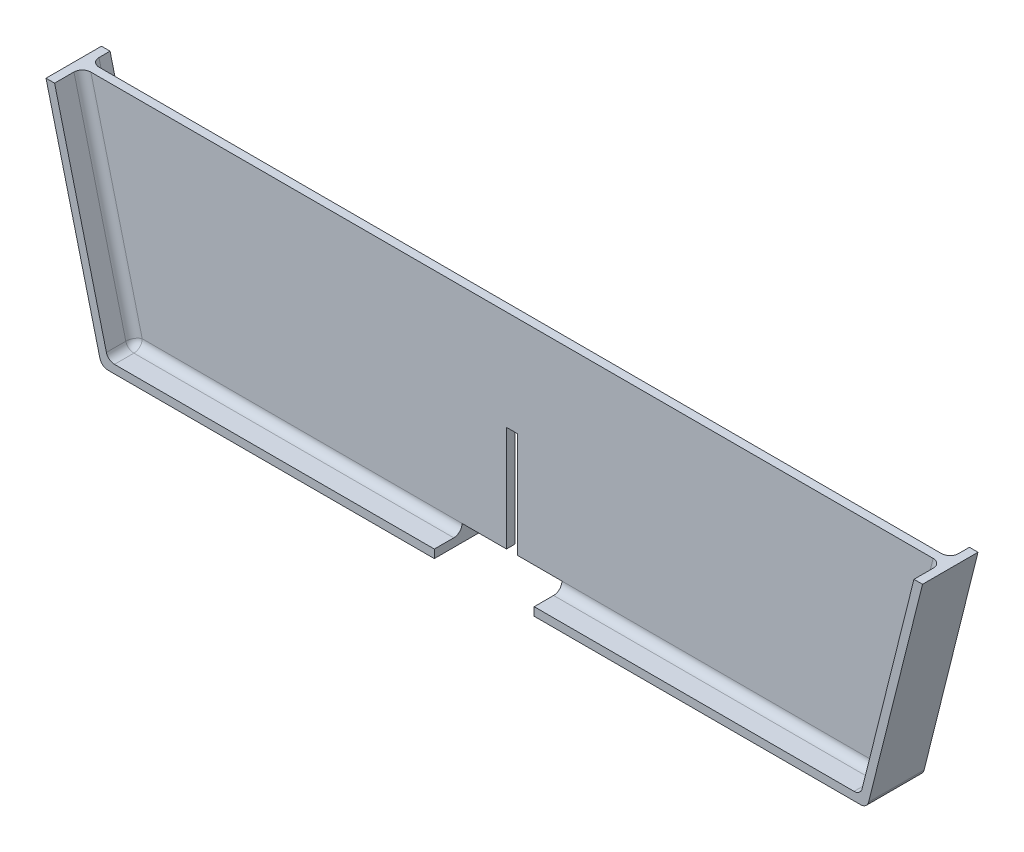
from build123d import *

# Parameters (mm, degrees)
BOSS_EXTRUDE2_DEPTH            = 1.5
BOSS_EXTRUDE3_DEPTH            = 5
BOSS_EXTRUDE3_DEPTH_BACK       = 5
FILLET1_R                      = 1.5
CUT_EXTRUDE1_REACH             = 7
SKETCH6_W                      = 8
SKETCH6_H                      = 3
CUT_EXTRUDE1_DIRECTION_2_DEPTH = 6


with BuildPart() as part:
    # Sketch1 → Boss-Extrude2 (new body)
    with BuildSketch(Plane.XY):
        Polygon((0, 0), (158, 0), (148, -40), (80, -40), (80, -18), (78, -18), (78, -40), (10, -40), align=None)
    extrude(amount=BOSS_EXTRUDE2_DEPTH)

    # Sketch5 → Boss-Extrude3 (add, two sides)
    with BuildSketch(Plane.XY.offset(1.5)) as boss_extrude3_sk:
        Polygon((156.45383539, 0), (158, 0), (148, -40), (88, -40), (88, -38.5), (146.82883539, -38.5), align=None)
        Polygon((70, -38.5), (70, -40), (10, -40), (0, 0), (1.54616461, 0), (11.17116461, -38.5), align=None)
    extrude(amount=BOSS_EXTRUDE3_DEPTH)
    extrude(boss_extrude3_sk.sketch, amount=-BOSS_EXTRUDE3_DEPTH_BACK)

    # Fillet1
    fillet1_edges = [part.edges().sort_by_distance(p)[0] for p in [
        (148, -40, 1.5),
        (10, -40, 1.5),
        (151.64133539, -19.25, 0),
        (117.414417695, -38.5, 0),
        (146.82883539, -38.5, -1.75),
        (117.414417695, -38.5, 1.5),
        (151.64133539, -19.25, 1.5),
        (146.82883539, -38.5, 4),
        (40.585582305, -38.5, 0),
        (6.35866461, -19.25, 0),
        (11.17116461, -38.5, -1.75),
        (6.35866461, -19.25, 1.5),
        (40.585582305, -38.5, 1.5),
        (11.17116461, -38.5, 4),
    ]]
    fillet(fillet1_edges, radius=FILLET1_R)

    # Sketch6 → Cut-Extrude1 (cut, up to next)
    with BuildSketch(Plane.XY.offset(1.5), mode=Mode.PRIVATE) as cut_extrude1_sk1:
        with Locations((74, -38.5)):
            Rectangle(SKETCH6_W, SKETCH6_H)
    cut_extrude1_tool1 = extrude(cut_extrude1_sk1.sketch, amount=-CUT_EXTRUDE1_REACH, mode=Mode.PRIVATE) & part.part
    add(cut_extrude1_tool1.solids().sort_by_distance((74, -38.5, 1.5))[0], mode=Mode.SUBTRACT)
    # Sketch6 → Cut-Extrude1 (cut, up to next)
    with BuildSketch(Plane.XY.offset(1.5), mode=Mode.PRIVATE) as cut_extrude1_sk2:
        with Locations((84, -38.5)):
            Rectangle(SKETCH6_W, SKETCH6_H)
    cut_extrude1_tool2 = extrude(cut_extrude1_sk2.sketch, amount=-CUT_EXTRUDE1_REACH, mode=Mode.PRIVATE) & part.part
    add(cut_extrude1_tool2.solids().sort_by_distance((84, -38.5, 1.5))[0], mode=Mode.SUBTRACT)

    # Sketch6 → Cut-Extrude1 direction 2 (cut)
    with BuildSketch(Plane.XY.offset(1.5)):
        with Locations((74, -38.5)):
            Rectangle(SKETCH6_W, SKETCH6_H)
        with Locations((84, -38.5)):
            Rectangle(SKETCH6_W, SKETCH6_H)
    extrude(amount=CUT_EXTRUDE1_DIRECTION_2_DEPTH, mode=Mode.SUBTRACT)


solid = part.part
